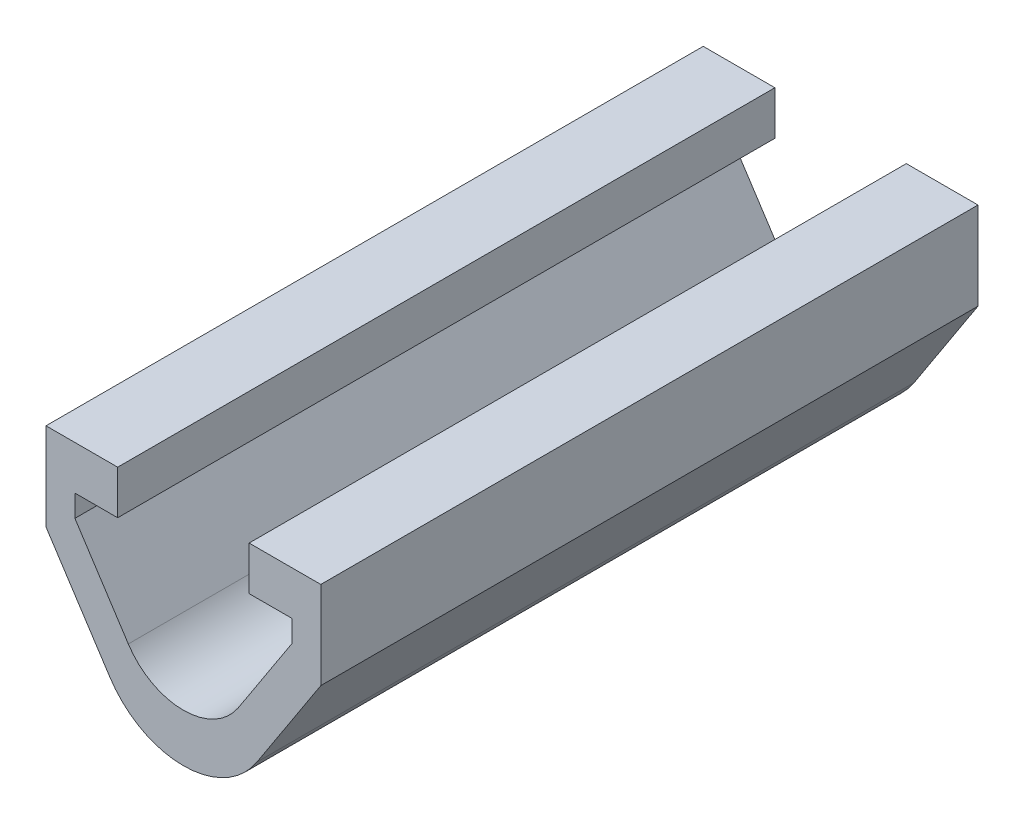
from build123d import *

# Parameters (mm, degrees)
BOSS_EXTRUDE2_DEPTH = 30


with BuildPart() as part:
    # Sketch1 → Boss-Extrude2 (new body)
    with BuildSketch(Plane.XY):
        with BuildLine():
            Line((3, -8.5), (4.952380952, -5.5))
            Line((4.952380952, -5.5), (4.952380952, -4.5))
            Line((4.952380952, -4.5), (3, -4.5))
            Line((3, -4.5), (3, -2.5))
            Line((3, -2.5), (6.271768379, -2.5))
            Line((6.271768379, -2.5), (6.271768379, -6.5))
            Line((6.271768379, -6.5), (3.35255813, -10.985615749))
            ThreePointArc((3.35255813, -10.985615749), (0, -12.803792203), (-3.35255813, -10.985615749))
            Line((-3.35255813, -10.985615749), (-6.271768379, -6.5))
            Line((-6.271768379, -6.5), (-6.271768379, -2.5))
            Line((-6.271768379, -2.5), (-3, -2.5))
            Line((-3, -2.5), (-3, -4.5))
            Line((-3, -4.5), (-4.952380952, -4.5))
            Line((-4.952380952, -4.5), (-4.952380952, -5.5))
            Line((-4.952380952, -5.5), (-3, -8.5))
            Line((-3, -8.5), (-2.514418598, -9.246137277))
            ThreePointArc((-2.514418598, -9.246137277), (0, -10.609769618), (2.514418598, -9.246137277))
            Line((2.514418598, -9.246137277), (3, -8.5))
        make_face()
    extrude(amount=BOSS_EXTRUDE2_DEPTH)


solid = part.part
